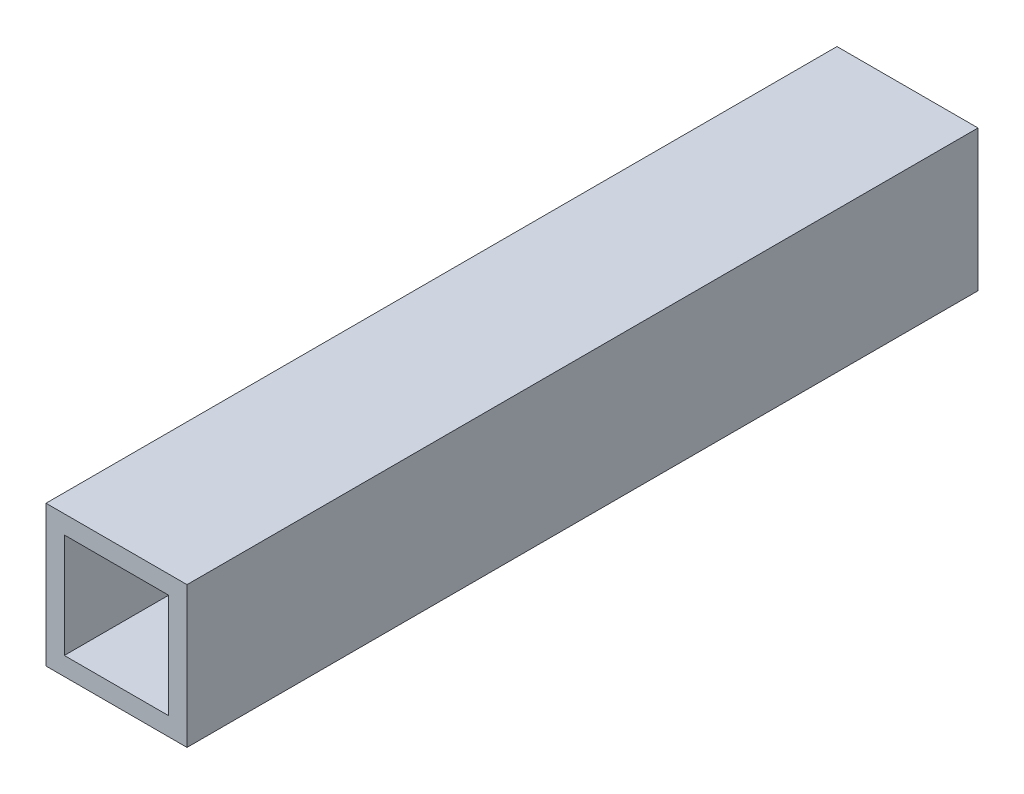
from build123d import *

# Parameters (mm, degrees)
SKETCH1_W           = 12.7
SKETCH1_H           = 12.7
SKETCH1_W_2         = 9.4
SKETCH1_H_2         = 9.4
BOSS_EXTRUDE1_DEPTH = 71.24


with BuildPart() as part:
    # Sketch1 → Boss-Extrude1 (new body)
    with BuildSketch(Plane.XY):
        Rectangle(SKETCH1_W, SKETCH1_H)
        Rectangle(SKETCH1_W_2, SKETCH1_H_2, mode=Mode.SUBTRACT)
    extrude(amount=BOSS_EXTRUDE1_DEPTH)


solid = part.part
